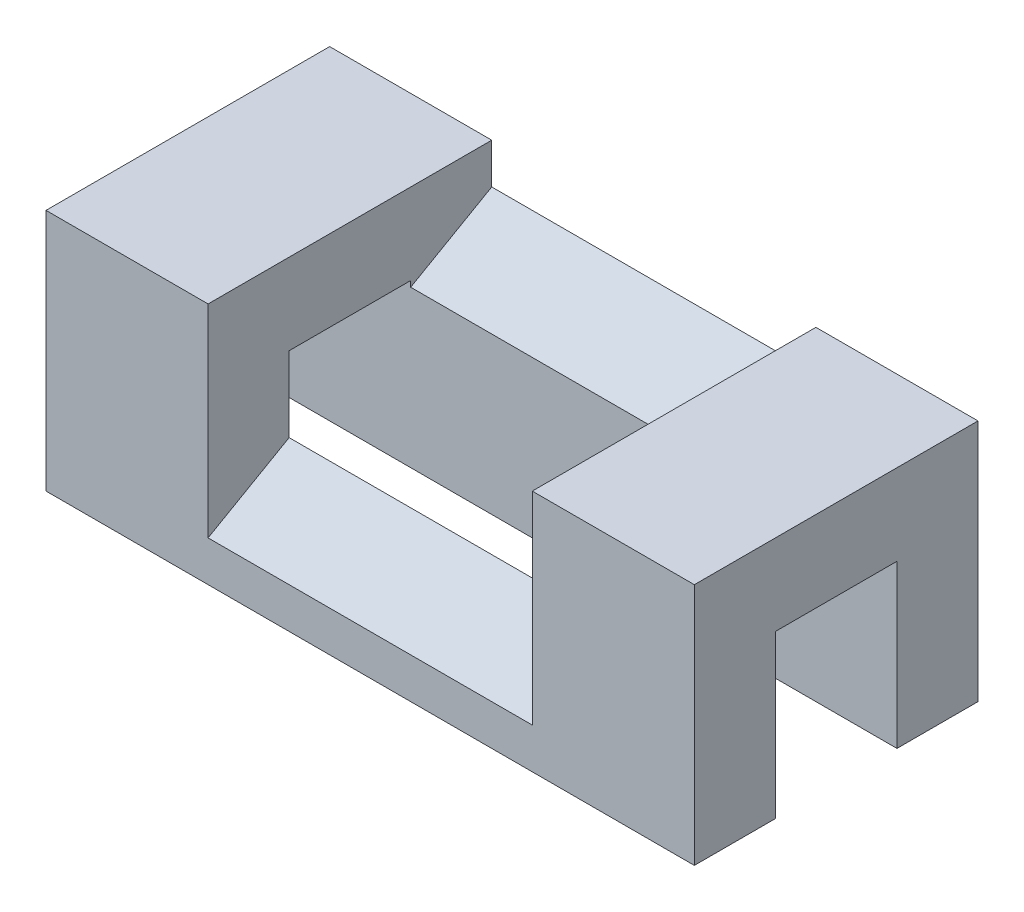
from build123d import *

# Parameters (mm, degrees)
BOSS_EXTRUDE1_DEPTH     = 80
CUT_EXTRUDE1_START      = -40
CUT_EXTRUDE1_DEPTH      = 20
CUT_EXTRUDE1_DEPTH_BACK = 20


with BuildPart() as part:
    # Sketch1 → Boss-Extrude1 (new body)
    with BuildSketch(Plane(origin=(0, 0, 0), x_dir=(0, 0, -1), z_dir=(1, 0, 0))):
        Polygon((0, 0), (0, 30), (35, 30), (35, 0), (25, 0), (25, 20), (10, 20), (10, 0), align=None)
    extrude(amount=-BOSS_EXTRUDE1_DEPTH)

    # Sketch2 → Cut-Extrude1 (cut, two sides)
    with BuildSketch(Plane(origin=(0, 0, 0), x_dir=(0, 0, -1), z_dir=(1, 0, 0)).offset(CUT_EXTRUDE1_START)) as cut_extrude1_sk:
        Polygon((35, 30), (35, 25), (0, 5), (0, 30), align=None)
    extrude(amount=CUT_EXTRUDE1_DEPTH, mode=Mode.SUBTRACT)
    extrude(cut_extrude1_sk.sketch, amount=-CUT_EXTRUDE1_DEPTH_BACK, mode=Mode.SUBTRACT)


solid = part.part
